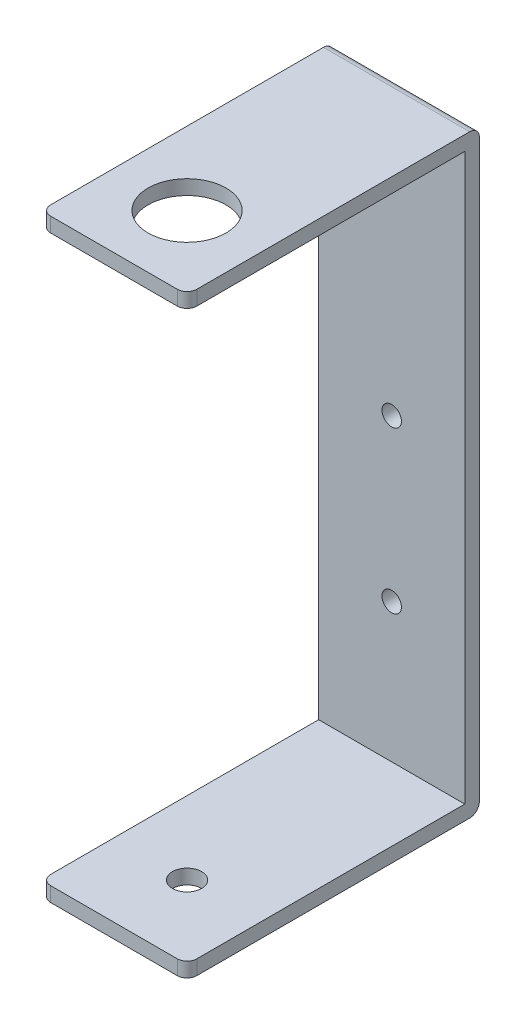
from build123d import *

# Parameters (mm, degrees)
BOSS_EXTRUDE1_DEPTH = 1.5
SKETCH2_W           = 15
SKETCH2_H           = 1.5
BOSS_EXTRUDE2_DEPTH = 28.5
SKETCH3_R           = 1.5
CUT_EXTRUDE1_DEPTH  = 62
FILLET1_R           = 1
CUT_EXTRUDE2_REACH  = 63
SKETCH5_R           = 4
SKETCH6_R           = 1
CUT_EXTRUDE3_DEPTH  = 10


with BuildPart() as part:
    # Sketch1 → Boss-Extrude1 (new body)
    with BuildSketch(Plane.XY):
        Polygon((-7.5, -23.042592662), (-7.5, -30.5), (7.5, -30.5), (7.5, -23.042592662), (7.5, 26.84732779), (7.5, 30.5), (-7.5, 30.5), (-7.5, 26.84732779), align=None)
    extrude(amount=BOSS_EXTRUDE1_DEPTH)

    # Sketch2 → Boss-Extrude2 (add)
    with BuildSketch(Plane.XY.offset(1.5)):
        with Locations((0, 29.75)):
            Rectangle(SKETCH2_W, SKETCH2_H)
        with Locations((0, -29.75)):
            Rectangle(SKETCH2_W, SKETCH2_H)
    extrude(amount=BOSS_EXTRUDE2_DEPTH)

    # Sketch3 → Cut-Extrude1 (cut, through all)
    with BuildSketch(Plane(origin=(0, 30.5, 0), x_dir=(1, 0, 0), z_dir=(0, 1, 0))):
        with Locations((0, -22.5)):
            Circle(SKETCH3_R)
    extrude(amount=-CUT_EXTRUDE1_DEPTH, mode=Mode.SUBTRACT)

    # Fillet1
    fillet1_edges = [part.edges().sort_by_distance(p)[0] for p in [
        (0, -30.5, 0),
        (-7.5, -29.75, 30),
        (7.5, -29.75, 30),
        (7.5, 29.75, 30),
        (-7.5, 29.75, 30),
        (0, 30.5, 0),
    ]]
    fillet(fillet1_edges, radius=FILLET1_R)

    # Sketch5 → Cut-Extrude2 (cut, up to next)
    with BuildSketch(Plane(origin=(0, 30.5, 0), x_dir=(1, 0, 0), z_dir=(0, 1, 0)), mode=Mode.PRIVATE) as cut_extrude2_sk1:
        with Locations((0, -22.5)):
            Circle(SKETCH5_R)
    cut_extrude2_tool1 = extrude(cut_extrude2_sk1.sketch, amount=-CUT_EXTRUDE2_REACH, mode=Mode.PRIVATE) & part.part
    add(cut_extrude2_tool1.solids().sort_by_distance((0, 30.5, 22.5))[0], mode=Mode.SUBTRACT)

    # Sketch6 → Cut-Extrude3 (cut)
    with BuildSketch(Plane.XY.offset(1.5)):
        with Locations((0, -14.75)):
            Circle(SKETCH6_R)
        with Locations((0, 1.762)):
            Circle(SKETCH6_R)
    extrude(amount=-CUT_EXTRUDE3_DEPTH, mode=Mode.SUBTRACT)


solid = part.part
